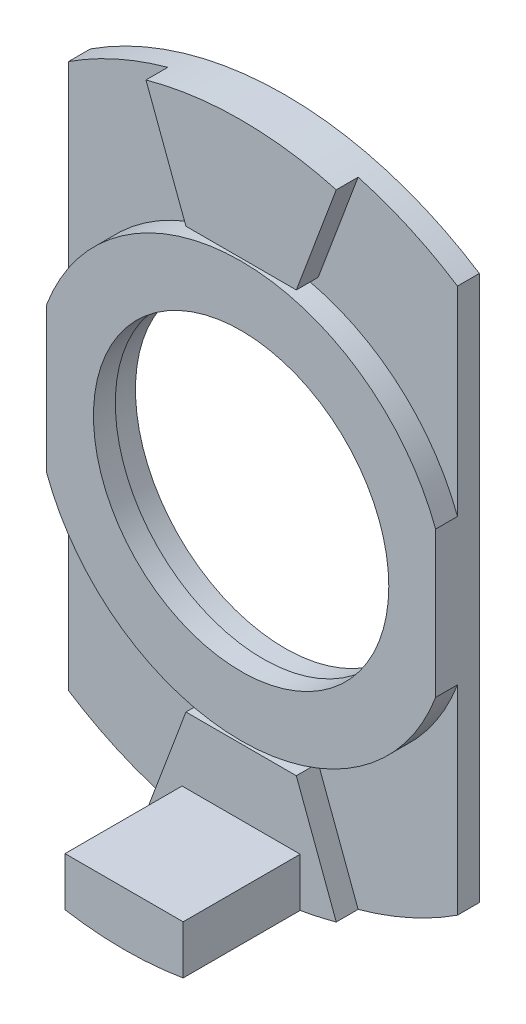
from build123d import *

# Parameters (mm, degrees)
SKETCH1_R           = 3.469974147
BOSS_EXTRUDE1_DEPTH = 0.508
BOSS_EXTRUDE2_DEPTH = 0.508
BOSS_EXTRUDE3_DEPTH = 2.7178
SKETCH4_R           = 3.429
BOSS_EXTRUDE4_DEPTH = 0.508


with BuildPart() as part:
    # Sketch1 → Boss-Extrude1 (new body)
    with BuildSketch(Plane.XY):
        with BuildLine():
            Line((-4.516012823, 6.325662964), (-4.516012823, -6.325662964))
            ThreePointArc((-4.516012823, -6.325662964), (0, -7.662131341), (4.516012823, -6.325662964))
            Line((4.516012823, -6.325662964), (4.516012823, 6.325662964))
            ThreePointArc((4.516012823, 6.325662964), (0, 7.662131341), (-4.516012823, 6.325662964))
        make_face()
        Circle(SKETCH1_R, mode=Mode.SUBTRACT)
    extrude(amount=BOSS_EXTRUDE1_DEPTH)

    # Sketch2 → Boss-Extrude2 (add)
    with BuildSketch(Plane.XY.offset(0.508)):
        with BuildLine():
            Line((2.209457086, -7.362582022), (1.281405607, -4.884037371))
            Line((1.281405607, -4.884037371), (-1.281405607, -4.884037371))
            Line((-1.281405607, -4.884037371), (-2.209457086, -7.362582022))
            ThreePointArc((-2.209457086, -7.362582022), (0, -7.662131341), (2.209457086, -7.362582022))
        make_face()
    boss_extrude2 = extrude(amount=BOSS_EXTRUDE2_DEPTH)

    # Sketch3 → Boss-Extrude3 (add)
    with BuildSketch(Plane.XY.offset(1.016)):
        with BuildLine():
            Line((-1.3716, -7.547991025), (-1.3716, -6.417691025))
            Line((-1.3716, -6.417691025), (1.3716, -6.417691025))
            Line((1.3716, -6.417691025), (1.3716, -7.547991025))
            ThreePointArc((1.3716, -7.547991025), (0, -7.662131341), (-1.3716, -7.547991025))
        make_face()
    extrude(amount=BOSS_EXTRUDE3_DEPTH)

    # Sketch4 → Boss-Extrude4 (add)
    with BuildSketch(Plane.XY.offset(0.508)):
        with BuildLine():
            Line((4.516012823, -1.692704651), (4.516012823, 1.692704651))
            ThreePointArc((4.516012823, 1.692704651), (0, 4.822822913), (-4.516012823, 1.692704651))
            Line((-4.516012823, 1.692704651), (-4.516012823, -1.692704651))
            ThreePointArc((-4.516012823, -1.692704651), (0, -4.822822913), (4.516012823, -1.692704651))
        make_face()
        Circle(SKETCH4_R, mode=Mode.SUBTRACT)
    extrude(amount=BOSS_EXTRUDE4_DEPTH)

    # Mirror1: Boss-Extrude2 across plane
    add(boss_extrude2.mirror(Plane.ZX))


solid = part.part
